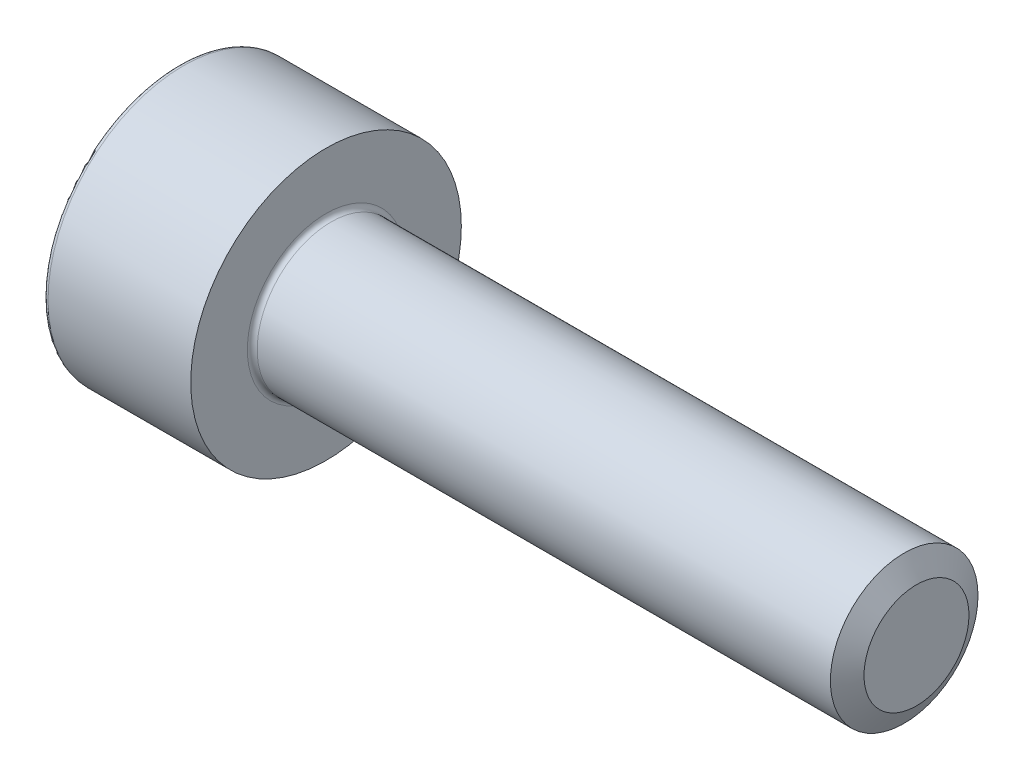
from build123d import *

# Parameters (mm, degrees)
SKETCH_1_W          = 3
SKETCH_1_H          = 2.75
SKETCH_2_R          = 1.5
EXTRUDE_1_DEPTH     = 12
CUT_EXTRUDE_1_DEPTH = 1.3
CHAMFER_1_SIZE      = 0.433
CHAMFER_1_SIZE2     = 0.25
FILLET_1_R          = 0.1


with BuildPart() as part:
    # 草图1 → 旋转1 (revolve)
    with BuildSketch(Plane.XY):
        with Locations((1.5, 1.375)):
            Rectangle(SKETCH_1_W, SKETCH_1_H)
    revolve(axis=Axis((0, 0, 0), (1, 0, 0)))

    # 草图2 → 凸台-拉伸1 (add)
    with BuildSketch(Plane(origin=(3, 0, 0), x_dir=(0, 0, -1), z_dir=(1, 0, 0))):
        Circle(SKETCH_2_R)
    extrude(amount=EXTRUDE_1_DEPTH)

    # 草图3 → 切除-拉伸1 (cut)
    with BuildSketch(Plane.ZY):
        Polygon((0, 1.435), (-1.242746454, 0.7175), (-1.242746454, -0.7175), (0, -1.435), (1.242746454, -0.7175), (1.242746454, 0.7175), align=None)
    extrude(amount=-CUT_EXTRUDE_1_DEPTH, mode=Mode.SUBTRACT)

    # 倒角1
    chamfer_1_edges = [part.edges().sort_by_distance(p)[0] for p in [
        (15, 0, 1.5),
    ]]
    chamfer_1_side = [part.faces().sort_by_distance(p)[0] for p in [
        (15, 0, 0),
    ]]
    chamfer(chamfer_1_edges, length=CHAMFER_1_SIZE, length2=CHAMFER_1_SIZE2, reference=chamfer_1_side[0])

    # 圆角1
    fillet_1_edges = [part.edges().sort_by_distance(p)[0] for p in [
        (0, -2.75, 0),
        (3, 0, 1.5),
    ]]
    fillet(fillet_1_edges, radius=FILLET_1_R)


solid = part.part
